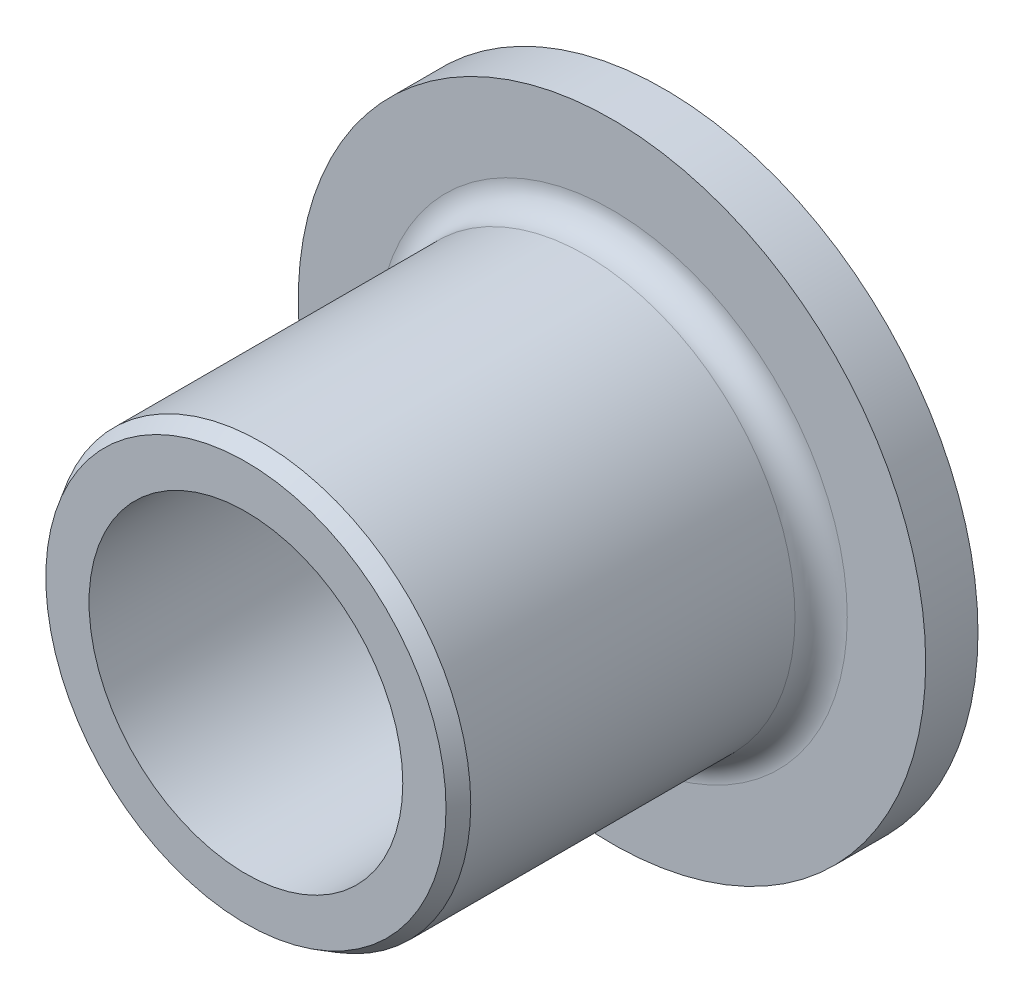
from build123d import *


with BuildPart() as part:
    # Sketch1 → Revolve1 (revolve)
    with BuildSketch(Plane(origin=(0, 0, 0), x_dir=(0, 0, -1), z_dir=(1, 0, 0))):
        with BuildLine():
            Line((0, 6), (-1, 6))
            Line((-1, 6), (-1, 4.5))
            ThreePointArc((-1, 4.5), (-1.146446609, 4.146446609), (-1.5, 4))
            Line((-1.5, 4), (-7.7, 4))
            Line((-7.7, 4), (-8, 3.826794919))
            Line((-8, 3.826794919), (-8, 3))
            Line((-8, 3), (0, 3))
            Line((0, 3), (0, 6))
        make_face()
    revolve(axis=Axis((0, 0, 0), (0, 0, -1)))


solid = part.part
